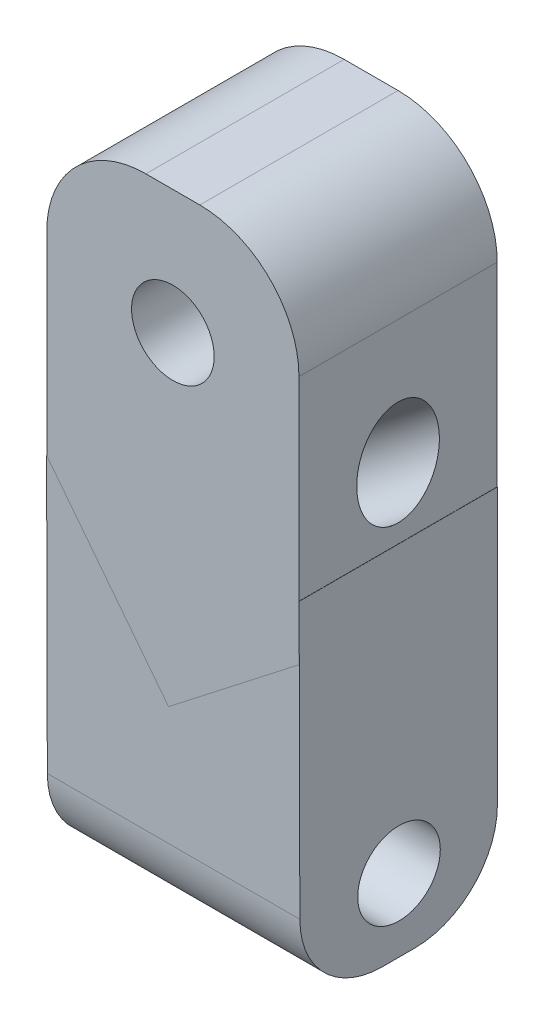
from build123d import *

# Parameters (mm, degrees)
SKETCH5_W           = 60
SKETCH5_H           = 60
SKETCH5_R           = 12.5
BOSS_EXTRUDE3_DEPTH = 25
SKETCH9_R           = 12.5
BOSS_EXTRUDE5_DEPTH = 30
SKETCH10_R          = 12.5
BOSS_EXTRUDE6_DEPTH = 38.21
SKETCH5_2_R         = 12.5
CUT_EXTRUDE2_DEPTH  = 115


with BuildPart() as part:
    # Sketch5 → Boss-Extrude3 (new, symmetric)
    with BuildSketch(Plane(origin=(0, 0, 0), x_dir=(0, 0, -1), z_dir=(0.7890840848346939, 0.6142852000989389, 0))):
        Rectangle(SKETCH5_W, SKETCH5_H)
        Circle(SKETCH5_R, mode=Mode.SUBTRACT)
    extrude(amount=BOSS_EXTRUDE3_DEPTH, both=True)

    # Sketch9 → Boss-Extrude5 (add, symmetric)
    with BuildSketch(Plane.XY):
        with BuildLine():
            Line((38.155658124, -8.315392543), (38.155658124, 67.179146139))
            ThreePointArc((38.155658124, 67.179146139), (29.368861559, 88.392349575), (8.155658124, 97.179146139))
            Line((8.155658124, 97.179146139), (-8.155658124, 97.179146139))
            ThreePointArc((-8.155658124, 97.179146139), (-29.368861559, 88.392349575), (-38.155658124, 67.179146139))
            Line((-38.155658124, 67.179146139), (-38.155658124, 8.315392543))
            Line((-38.155658124, 8.315392543), (38.155658124, -8.315392543))
        make_face()
        with Locations((0, 59.597275262)):
            Circle(SKETCH9_R, mode=Mode.SUBTRACT)
    extrude(amount=BOSS_EXTRUDE5_DEPTH, both=True)

    # Sketch10 → Boss-Extrude6 (add, symmetric)
    with BuildSketch(Plane(origin=(0, 0, 0), x_dir=(0, 0, -1), z_dir=(1, 0, 0))):
        with BuildLine():
            Line((-4.782552043, -100.050547257), (5, -100.050547257))
            ThreePointArc((5, -100.050547257), (22.67766953, -92.728216787), (30, -75.050547257))
            Line((30, -75.050547257), (30, 8.315392543))
            Line((30, 8.315392543), (-30, 8.315392543))
            Line((-30, 8.315392543), (-29.782467066, -75.115730425))
            ThreePointArc((-29.782467066, -75.115730425), (-22.437160802, -92.751247514), (-4.782552043, -100.050547257))
        make_face()
        with Locations((0.225286959, -78.050547257)):
            Circle(SKETCH10_R, mode=Mode.SUBTRACT)
    extrude(amount=BOSS_EXTRUDE6_DEPTH, both=True)

    # Sketch5_2 → Cut-Extrude2 (cut, symmetric)
    with BuildSketch(Plane(origin=(0, 0, 0), x_dir=(0, 0, -1), z_dir=(0.7890840848346939, 0.6142852000989389, 0))):
        Circle(SKETCH5_2_R)
    extrude(amount=CUT_EXTRUDE2_DEPTH, both=True, mode=Mode.SUBTRACT)


solid = part.part
